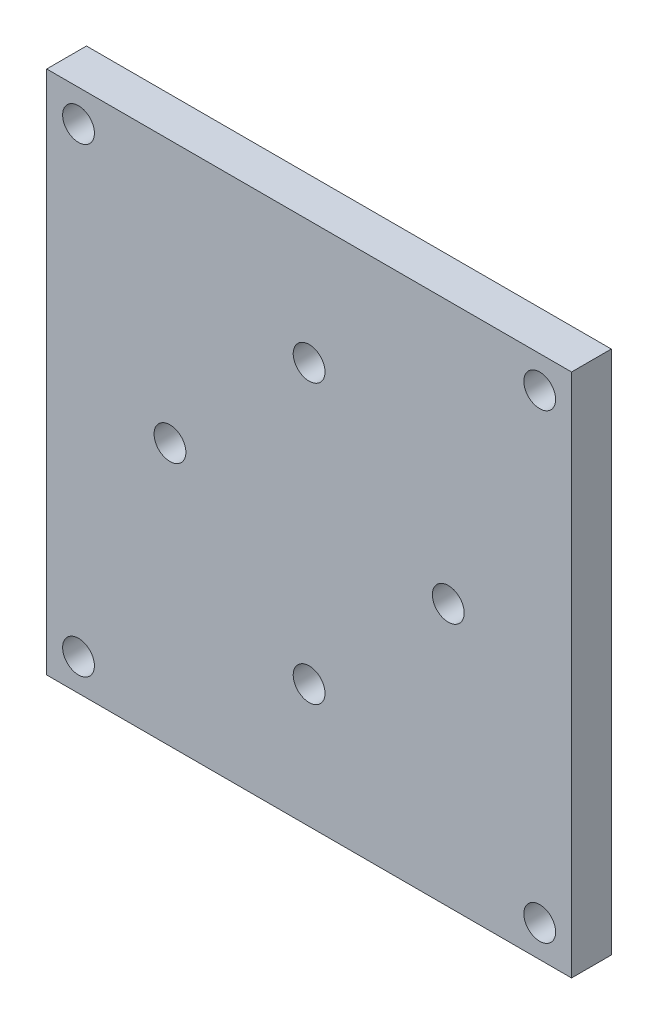
from build123d import *

# Parameters (mm, degrees)
SKETCH1_W           = 66
SKETCH1_H           = 66
BOSS_EXTRUDE1_DEPTH = 2.5
SKETCH2_R           = 2
CUT_EXTRUDE1_DEPTH  = 6
SKETCH3_R           = 2
CUT_EXTRUDE2_DEPTH  = 6


with BuildPart() as part:
    # Sketch1 → Boss-Extrude1 (new body, symmetric)
    with BuildSketch(Plane.XY):
        Rectangle(SKETCH1_W, SKETCH1_H)
    extrude(amount=BOSS_EXTRUDE1_DEPTH, both=True)

    # Sketch2 → Cut-Extrude1 (cut, through all)
    with BuildSketch(Plane.XY.offset(2.5)):
        with Locations((-29, 29)):
            Circle(SKETCH2_R)
        with Locations((29, 29)):
            Circle(SKETCH2_R)
        with Locations((29, -29)):
            Circle(SKETCH2_R)
        with Locations((-29, -29)):
            Circle(SKETCH2_R)
    extrude(amount=-CUT_EXTRUDE1_DEPTH, mode=Mode.SUBTRACT)

    # Sketch3 → Cut-Extrude2 (cut, through all)
    with BuildSketch(Plane.XY.offset(2.5)):
        with Locations((0, 17.5)):
            Circle(SKETCH3_R)
        with Locations((17.5, 0)):
            Circle(SKETCH3_R)
        with Locations((0, -17.5)):
            Circle(SKETCH3_R)
        with Locations((-17.5, 0)):
            Circle(SKETCH3_R)
    extrude(amount=-CUT_EXTRUDE2_DEPTH, mode=Mode.SUBTRACT)


solid = part.part
